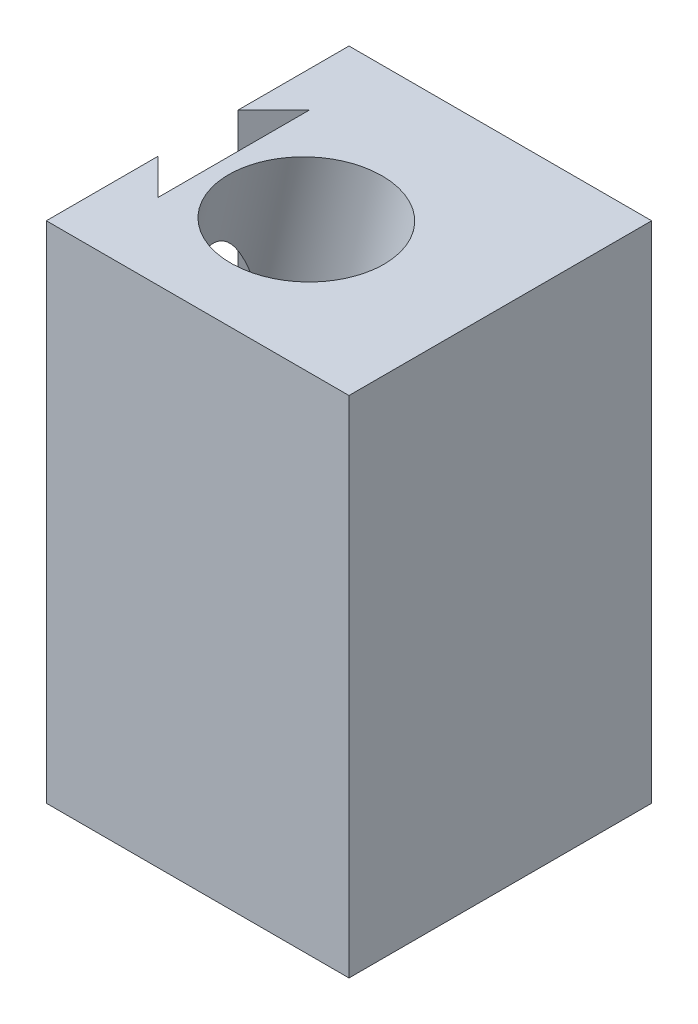
from build123d import *

# Parameters (mm, degrees)
BOSS_EXTRUDE1_DEPTH = 50
SKETCH4_R           = 7.5
CUT_EXTRUDE1_DEPTH  = 30
SKETCH5_R           = 4.5
CUT_EXTRUDE2_DEPTH  = 26.46703487


with BuildPart() as part:
    # Sketch2 → Boss-Extrude1 (new body)
    with BuildSketch(Plane(origin=(0, 0, 0), x_dir=(1, 0, 0), z_dir=(0, 1, 0))):
        Polygon((3.535533906, 22.535533906), (3.535533906, 7.535533906), (0, 11.071067812), (0, 0), (30, 0), (30, 30), (0, 30), (0, 19), align=None)
    extrude(amount=BOSS_EXTRUDE1_DEPTH)

    # Sketch4 → Cut-Extrude1 (cut)
    with BuildSketch(Plane(origin=(12.477367975, 54.045418359, 0), x_dir=(0, 0, -1), z_dir=(0.224951054, 0.974370065, 0))):
        with Locations((13, -1.197365684)):
            Circle(SKETCH4_R)
    extrude(amount=-CUT_EXTRUDE1_DEPTH, mode=Mode.SUBTRACT)

    # Sketch5 → Cut-Extrude2 (cut, through all)
    with BuildSketch(Plane(origin=(5.728836345, 24.814316416, 0), x_dir=(0.974370065, -0.224951054, 0), z_dir=(0.224951054, 0.974370065, 0))):
        with Locations((1.197365684, 13)):
            Circle(SKETCH5_R)
    extrude(amount=-CUT_EXTRUDE2_DEPTH, mode=Mode.SUBTRACT)


solid = part.part
